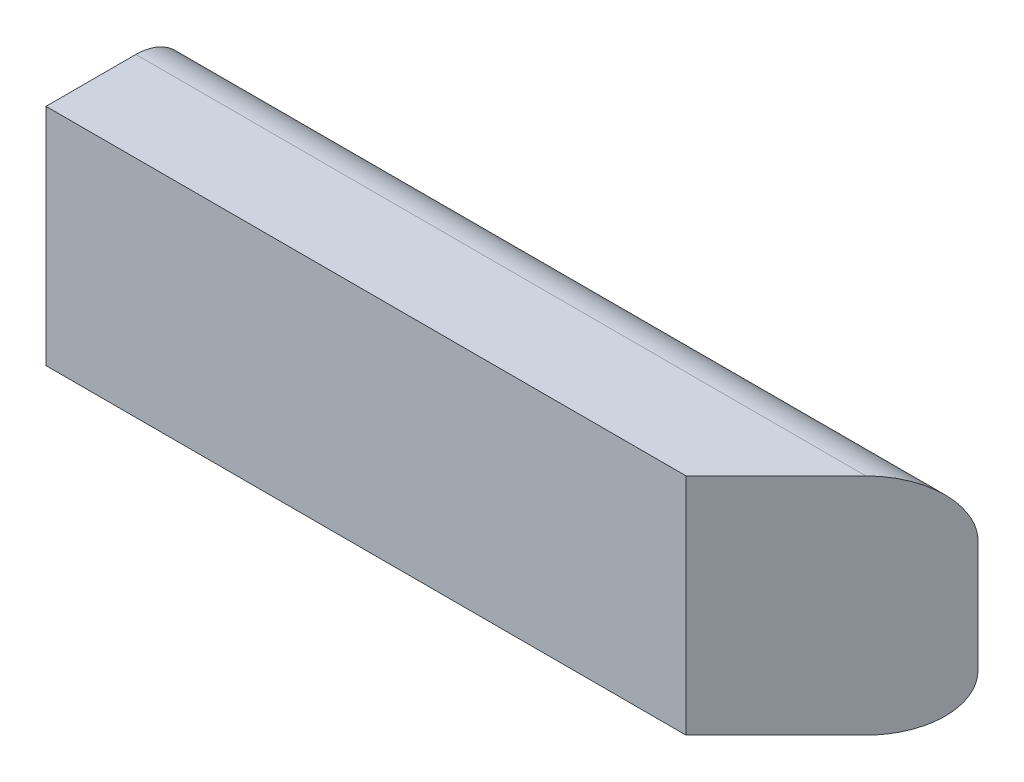
from build123d import *

# Parameters (mm, degrees)
BOSS_EXTRUDE1_DEPTH = 444.5
SKETCH2_W           = 344.402501539
SKETCH2_H           = 780.457540958
CUT_EXTRUDE1_DEPTH  = 59.371664787


with BuildPart() as part:
    # Sketch1 → Boss-Extrude1 (new body)
    with BuildSketch(Plane(origin=(0, 0, 0), x_dir=(0, 0, -1), z_dir=(1, 0, 0))):
        with BuildLine():
            Line((0, 0), (31.75, 0))
            ThreePointArc((31.75, 0), (54.200640303, 9.299359697), (63.5, 31.75))
            Line((63.5, 31.75), (63.5, 95.25))
            ThreePointArc((63.5, 95.25), (54.200640303, 117.700640303), (31.75, 127))
            Line((31.75, 127), (0, 127))
            Line((0, 127), (-19.05, 127))
            Line((-19.05, 127), (-19.05, 0))
            Line((-19.05, 0), (0, 0))
        make_face()
    extrude(amount=BOSS_EXTRUDE1_DEPTH)

    # Sketch2 → Cut-Extrude1 (cut, through all)
    with BuildSketch(Plane(origin=(190.5, 0, 190.5), x_dir=(0, 1, 0), z_dir=(0.707106781, 0, 0.707106781))):
        with Locations((32.995160032, -359.210244843)):
            Rectangle(SKETCH2_W, SKETCH2_H)
    extrude(amount=CUT_EXTRUDE1_DEPTH, mode=Mode.SUBTRACT)


solid = part.part
